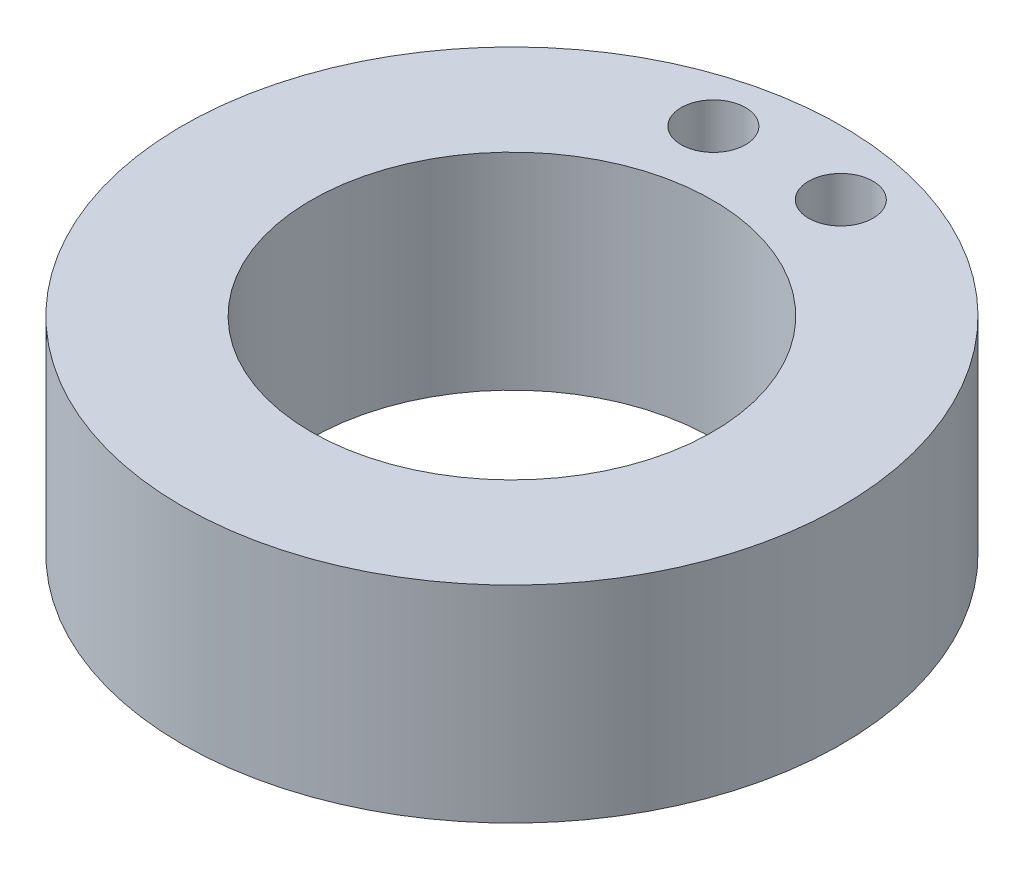
from build123d import *

# Parameters (mm, degrees)
SKETCH1_R           = 16.2433
SKETCH1_R_2         = 9.8933
BOSS_EXTRUDE1_DEPTH = 10.16
SKETCH2_R           = 1.5875
CUT_EXTRUDE2_DEPTH  = 11.16


with BuildPart() as part:
    # Sketch1 → Boss-Extrude1 (new body)
    with BuildSketch(Plane(origin=(0, 0, 0), x_dir=(1, 0, 0), z_dir=(0, 1, 0))):
        Circle(SKETCH1_R)
        Circle(SKETCH1_R_2, mode=Mode.SUBTRACT)
    extrude(amount=BOSS_EXTRUDE1_DEPTH)

    # Sketch2 → Cut-Extrude2 (cut, through all)
    with BuildSketch(Plane(origin=(0, 10.16, 0), x_dir=(1, 0, 0), z_dir=(0, 1, 0))):
        with Locations((-3.140315604, 13.0683)):
            Circle(SKETCH2_R)
        with Locations((3.140315604, 13.0683)):
            Circle(SKETCH2_R)
    extrude(amount=-CUT_EXTRUDE2_DEPTH, mode=Mode.SUBTRACT)


solid = part.part
